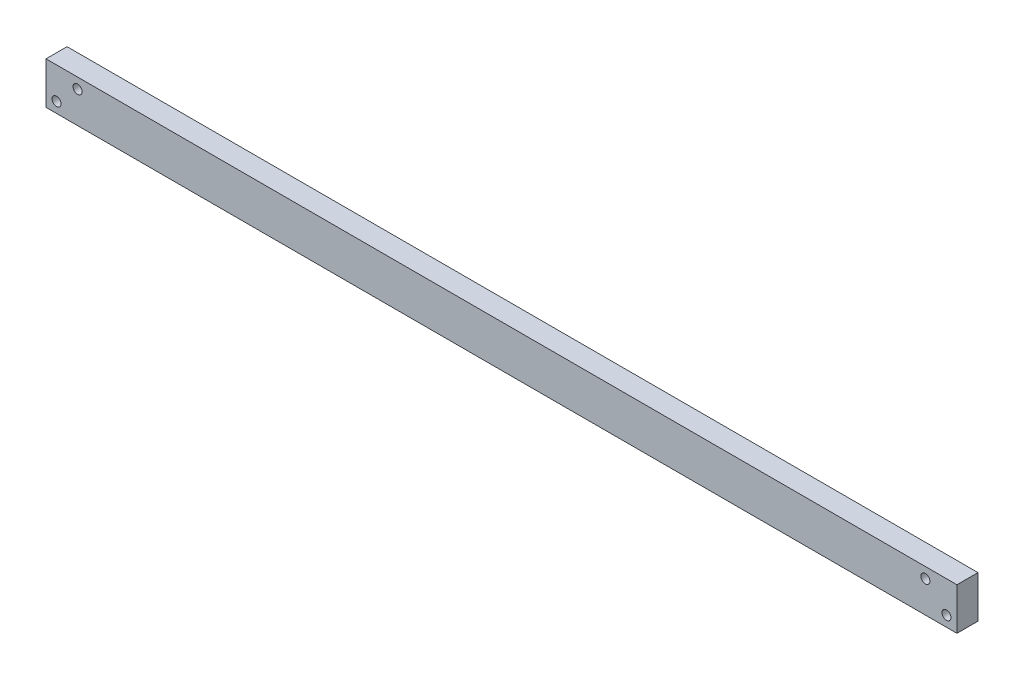
from build123d import *

# Parameters (mm, degrees)
IZIM1_W                     = 606
IZIM1_H                     = 28
Y_KSEKLIK_EKSTR_ZYON1_DEPTH = 14
KES_EKSTR_ZYON1_REACH       = 16
IZIM2_R                     = 3


with BuildPart() as part:
    # Çizim1 → Yükseklik-Ekstrüzyon1 (new body)
    with BuildSketch(Plane.XY):
        Rectangle(IZIM1_W, IZIM1_H)
    extrude(amount=Y_KSEKLIK_EKSTR_ZYON1_DEPTH)

    # Çizim2 → Kes-Ekstrüzyon1 (cut, up to next)
    with BuildSketch(Plane.XY.offset(14), mode=Mode.PRIVATE) as kes_ekstr_zyon1_sk1:
        with Locations((-282, 7)):
            Circle(IZIM2_R)
    kes_ekstr_zyon1_tool1 = extrude(kes_ekstr_zyon1_sk1.sketch, amount=-KES_EKSTR_ZYON1_REACH, mode=Mode.PRIVATE) & part.part
    add(kes_ekstr_zyon1_tool1.solids().sort_by_distance((-282, 7, 14))[0], mode=Mode.SUBTRACT)
    # Çizim2 → Kes-Ekstrüzyon1 (cut, up to next)
    with BuildSketch(Plane.XY.offset(14), mode=Mode.PRIVATE) as kes_ekstr_zyon1_sk2:
        with Locations((-296, -7)):
            Circle(IZIM2_R)
    kes_ekstr_zyon1_tool2 = extrude(kes_ekstr_zyon1_sk2.sketch, amount=-KES_EKSTR_ZYON1_REACH, mode=Mode.PRIVATE) & part.part
    add(kes_ekstr_zyon1_tool2.solids().sort_by_distance((-296, -7, 14))[0], mode=Mode.SUBTRACT)
    # Çizim2 → Kes-Ekstrüzyon1 (cut, up to next)
    with BuildSketch(Plane.XY.offset(14), mode=Mode.PRIVATE) as kes_ekstr_zyon1_sk3:
        with Locations((296, -7)):
            Circle(IZIM2_R)
    kes_ekstr_zyon1_tool3 = extrude(kes_ekstr_zyon1_sk3.sketch, amount=-KES_EKSTR_ZYON1_REACH, mode=Mode.PRIVATE) & part.part
    add(kes_ekstr_zyon1_tool3.solids().sort_by_distance((296, -7, 14))[0], mode=Mode.SUBTRACT)
    # Çizim2 → Kes-Ekstrüzyon1 (cut, up to next)
    with BuildSketch(Plane.XY.offset(14), mode=Mode.PRIVATE) as kes_ekstr_zyon1_sk4:
        with Locations((282, 7)):
            Circle(IZIM2_R)
    kes_ekstr_zyon1_tool4 = extrude(kes_ekstr_zyon1_sk4.sketch, amount=-KES_EKSTR_ZYON1_REACH, mode=Mode.PRIVATE) & part.part
    add(kes_ekstr_zyon1_tool4.solids().sort_by_distance((282, 7, 14))[0], mode=Mode.SUBTRACT)


solid = part.part
